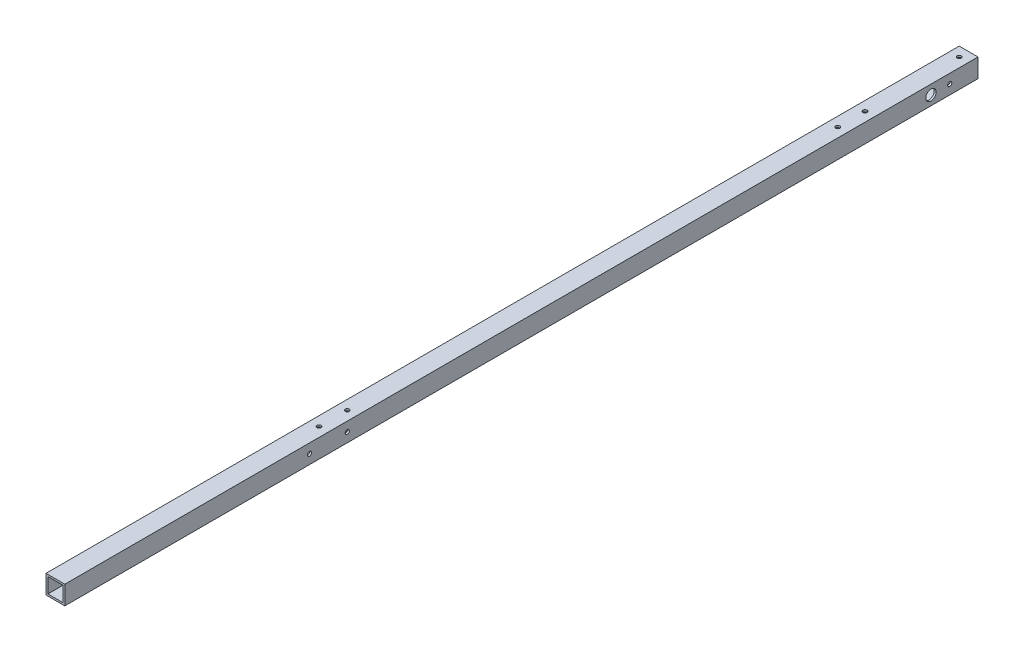
from build123d import *

# Parameters (mm, degrees)
SKETCH_1_W          = 20
SKETCH_1_H          = 20
SKETCH_1_W_2        = 16
SKETCH_1_H_2        = 16
EXTRUDE_1_DEPTH     = 970
SKETCH_2_R          = 2.2
SKETCH_2_R_2        = 5.5
CUT_EXTRUDE_1_DEPTH = 970
SKETCH_3_R          = 2.2
CUT_EXTRUDE_2_DEPTH = 970
SKETCH_5_R          = 2.2
CUT_EXTRUDE_4_DEPTH = 30


with BuildPart() as part:
    # ｽｹｯﾁ1 → ﾎﾞｽ - 押し出し1 (new body)
    with BuildSketch(Plane.XY):
        Rectangle(SKETCH_1_W, SKETCH_1_H)
        Rectangle(SKETCH_1_W_2, SKETCH_1_H_2, mode=Mode.SUBTRACT)
    extrude(amount=EXTRUDE_1_DEPTH)

    # ｽｹｯﾁ2 → ｶｯﾄ - 押し出し1 (cut)
    with BuildSketch(Plane(origin=(10, 0, 0), x_dir=(0, 0, -1), z_dir=(1, 0, 0))):
        with Locations((-710, 0)):
            Circle(SKETCH_2_R)
        with Locations((-670, 0)):
            Circle(SKETCH_2_R)
        with Locations((-50, 0)):
            Circle(SKETCH_2_R_2)
        with Locations((-30, 0)):
            Circle(SKETCH_2_R)
    extrude(amount=-CUT_EXTRUDE_1_DEPTH, mode=Mode.SUBTRACT)

    # ｽｹｯﾁ3 → ｶｯﾄ - 押し出し2 (cut)
    with BuildSketch(Plane(origin=(0, 10, 0), x_dir=(1, 0, 0), z_dir=(0, 1, 0))):
        with Locations((0, -690)):
            Circle(SKETCH_3_R)
        with Locations((0, -660)):
            Circle(SKETCH_3_R)
        with Locations((0, -10)):
            Circle(SKETCH_3_R)
    extrude(amount=-CUT_EXTRUDE_2_DEPTH, mode=Mode.SUBTRACT)

    # ｽｹｯﾁ5 → ｶｯﾄ - 押し出し4 (cut)
    with BuildSketch(Plane(origin=(0, 10, 0), x_dir=(1, 0, 0), z_dir=(0, 1, 0))):
        with Locations((0, -110)):
            Circle(SKETCH_5_R)
        with Locations((0, -139)):
            Circle(SKETCH_5_R)
    extrude(amount=-CUT_EXTRUDE_4_DEPTH, mode=Mode.SUBTRACT)


solid = part.part
